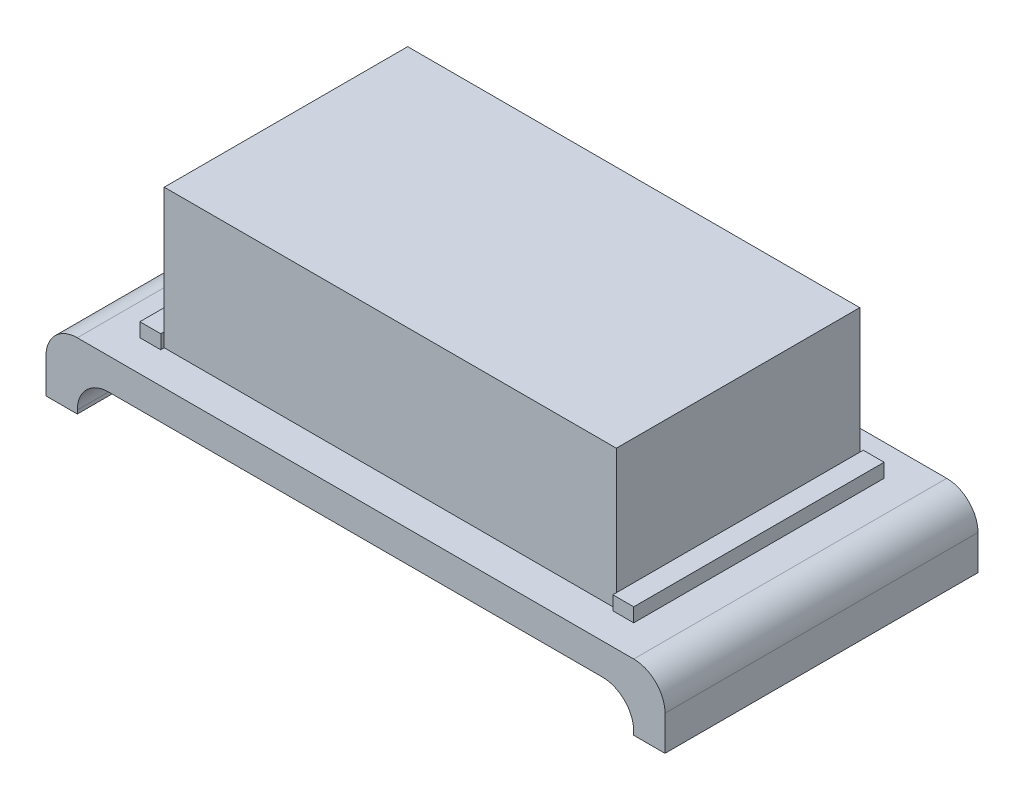
from build123d import *

# Parameters (mm, degrees)
ESQUISSE2_W              = 160
ESQUISSE2_H              = 90
EXTRUSION1_DEPTH         = 9
ESQUISSE1_W              = 130
ESQUISSE1_H              = 70
BEURRE_AVEC_MARGES_DEPTH = 40
ESQUISSE4_W              = 6
ESQUISSE4_H              = 72
EXTRUSION3_DEPTH         = 4
ESQUISSE6_W              = 9
ESQUISSE6_H              = 90
EXTRUSION4_DEPTH         = 19
CONG_1_R                 = 9


with BuildPart() as part:
    # Esquisse2 → Extrusion1 (new body)
    with BuildSketch(Plane(origin=(0, 0, 0), x_dir=(1, 0, 0), z_dir=(0, 1, 0))):
        with Locations((18.862465753, -11.339726027)):
            Rectangle(ESQUISSE2_W, ESQUISSE2_H)
    extrude(amount=-EXTRUSION1_DEPTH)

    # Esquisse1 → Beurre (avec marges) (add)
    with BuildSketch(Plane(origin=(0, 0, 0), x_dir=(1, 0, 0), z_dir=(0, 1, 0))):
        with Locations((18.862465753, -11.339726027)):
            Rectangle(ESQUISSE1_W, ESQUISSE1_H)
    extrude(amount=BEURRE_AVEC_MARGES_DEPTH)

    # Esquisse4 → Extrusion3 (add)
    with BuildSketch(Plane(origin=(0, 0, 0), x_dir=(1, 0, 0), z_dir=(0, 1, 0))):
        with Locations((-49.137534247, -11.339726027)):
            Rectangle(ESQUISSE4_W, ESQUISSE4_H)
        with Locations((86.862465753, -11.339726027)):
            Rectangle(ESQUISSE4_W, ESQUISSE4_H)
    extrude(amount=EXTRUSION3_DEPTH)

    # Esquisse6 → Extrusion4 (add)
    with BuildSketch(Plane(origin=(0, 0, 0), x_dir=(1, 0, 0), z_dir=(0, 1, 0))):
        with Locations((-65.637534247, -11.339726027)):
            Rectangle(ESQUISSE6_W, ESQUISSE6_H)
        with Locations((103.362465753, -11.339726027)):
            Rectangle(ESQUISSE6_W, ESQUISSE6_H)
    extrude(amount=-EXTRUSION4_DEPTH)

    # Congé1
    cong_1_edges = [part.edges().sort_by_distance(p)[0] for p in [
        (98.862465753, -9, 11.339726027),
        (-61.137534247, -9, 11.339726027),
        (107.862465753, 0, 11.339726027),
        (-70.137534247, 0, 11.339726027),
    ]]
    fillet(cong_1_edges, radius=CONG_1_R)


solid = part.part
